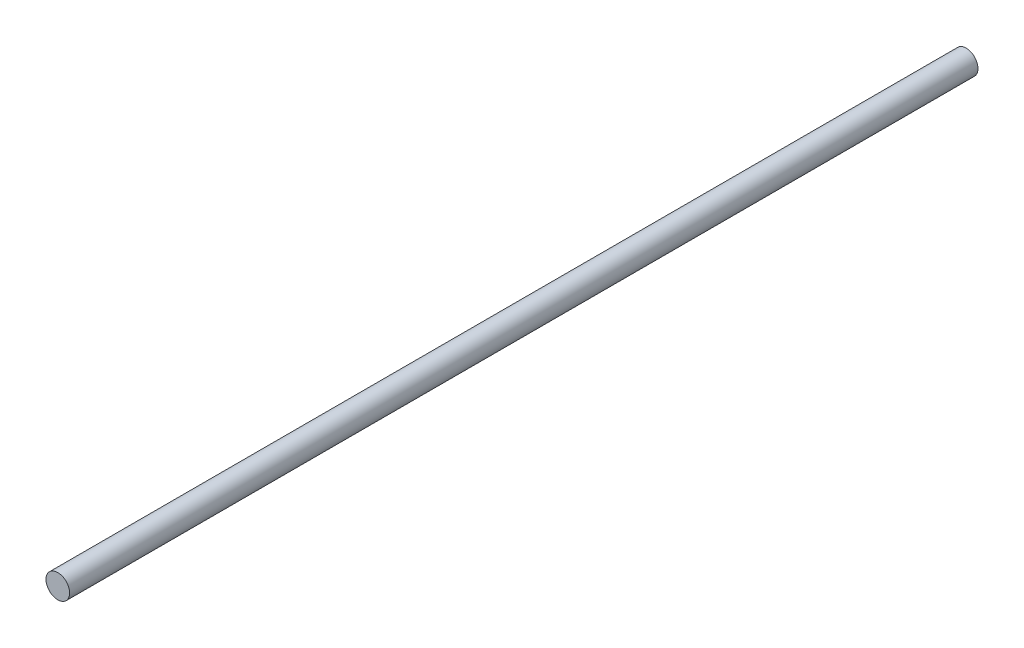
from build123d import *

# Parameters (mm, degrees)
SKETCH1_R           = 3.96875
BOSS_EXTRUDE1_DEPTH = 304.8


with BuildPart() as part:
    # Sketch1 → Boss-Extrude1 (new body)
    with BuildSketch(Plane.XY):
        Circle(SKETCH1_R)
    extrude(amount=BOSS_EXTRUDE1_DEPTH)


solid = part.part
